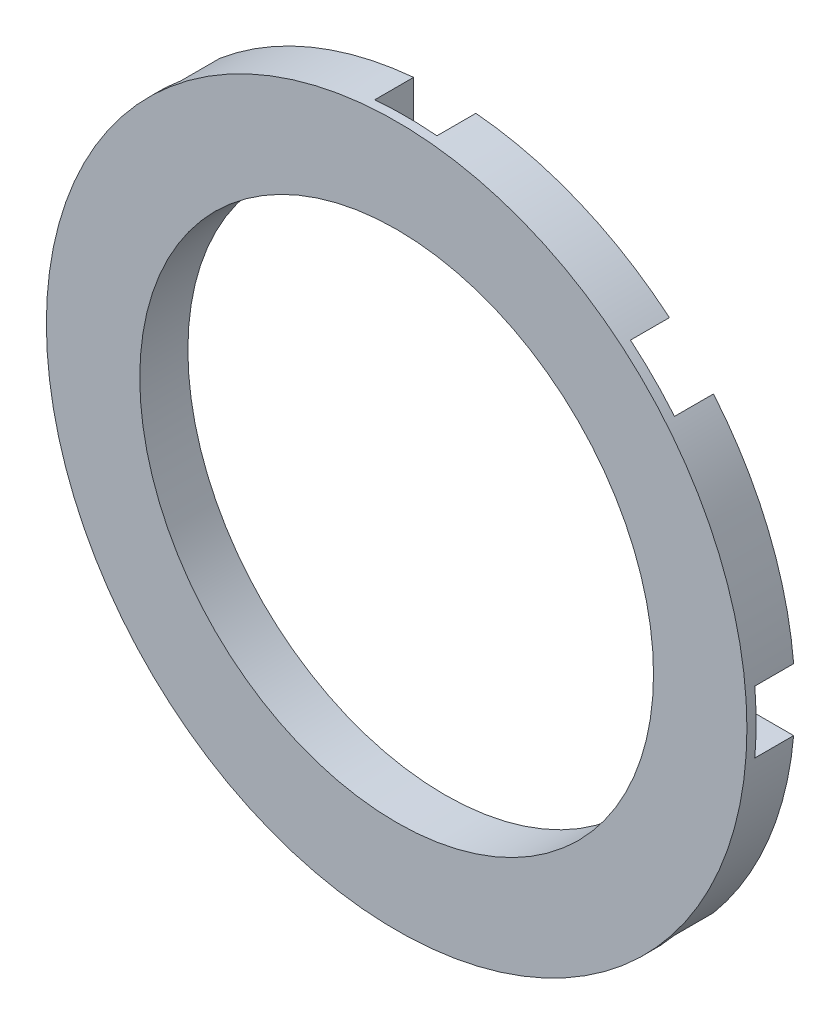
from build123d import *

# Parameters (mm, degrees)
SKETCH1_R                 = 28.575
SKETCH1_R_2               = 20.955
BOSS_EXTRUDE1_DEPTH       = 1.96215
BOSS_EXTRUDE1_DEPTH_BACK  = 1.96215
F_0_80_TAPPED_HOLE1_D     = 1.19126
F_0_80_TAPPED_HOLE1_DEPTH = 3.302
F_0_80_TAPPED_HOLE1_TIP   = 0.357890611
SKETCH4_R                 = 25.4
SKETCH4_R_2               = 22.225
CUT_EXTRUDE2_DEPTH        = 3.175
CUT_EXTRUDE3_DEPTH        = 3.175
CIRPATTERN1_COUNT         = 8


with BuildPart() as part:
    # Sketch1 → Boss-Extrude1 (new body, two sides)
    with BuildSketch(Plane.XY) as boss_extrude1_sk:
        Circle(SKETCH1_R)
        Circle(SKETCH1_R_2, mode=Mode.SUBTRACT)
    extrude(amount=BOSS_EXTRUDE1_DEPTH)
    extrude(boss_extrude1_sk.sketch, amount=-BOSS_EXTRUDE1_DEPTH_BACK)

    # #0-80 Tapped Hole1
    with Locations(Plane(origin=(0, 28.575, 0.041948097), x_dir=(1, 0, 0), z_dir=(0, 1, 0))):
        with Locations((0, 0)):
            Hole(F_0_80_TAPPED_HOLE1_D / 2, depth=F_0_80_TAPPED_HOLE1_DEPTH)
            with Locations((0, 0, -(F_0_80_TAPPED_HOLE1_DEPTH + F_0_80_TAPPED_HOLE1_TIP / 2))):  # 118° drill point
                Cone(0, F_0_80_TAPPED_HOLE1_D / 2, F_0_80_TAPPED_HOLE1_TIP, mode=Mode.SUBTRACT)

    # Sketch4 → Cut-Extrude2 (cut)
    with BuildSketch(Plane(origin=(0, 0, -1.96215), x_dir=(-1, 0, 0), z_dir=(0, 0, -1))):
        Circle(SKETCH4_R)
        Circle(SKETCH4_R_2, mode=Mode.SUBTRACT)
    extrude(amount=-CUT_EXTRUDE2_DEPTH, mode=Mode.SUBTRACT)

    # Sketch5 → Cut-Extrude3 (cut)
    with BuildSketch(Plane(origin=(0, 0, -1.96215), x_dir=(-1, 0, 0), z_dir=(0, 0, -1))):
        with BuildLine():
            Line((2.54, 31.115), (2.54, 24.765))
            ThreePointArc((2.54, 24.765), (0, 22.225), (-2.54, 24.765))
            Line((-2.54, 24.765), (-2.54, 31.115))
            ThreePointArc((-2.54, 31.115), (0, 33.655), (2.54, 31.115))
        make_face()
    cut_extrude3 = extrude(amount=-CUT_EXTRUDE3_DEPTH, mode=Mode.SUBTRACT)

    # CirPattern1: Cut-Extrude3 ×8 about axis
    cirpattern1_axis = Axis((0, 0, 0), (0, 0, 1))
    for i in range(1, CIRPATTERN1_COUNT):
        add(cut_extrude3.rotate(cirpattern1_axis, i * 360 / CIRPATTERN1_COUNT), mode=Mode.SUBTRACT)


solid = part.part
